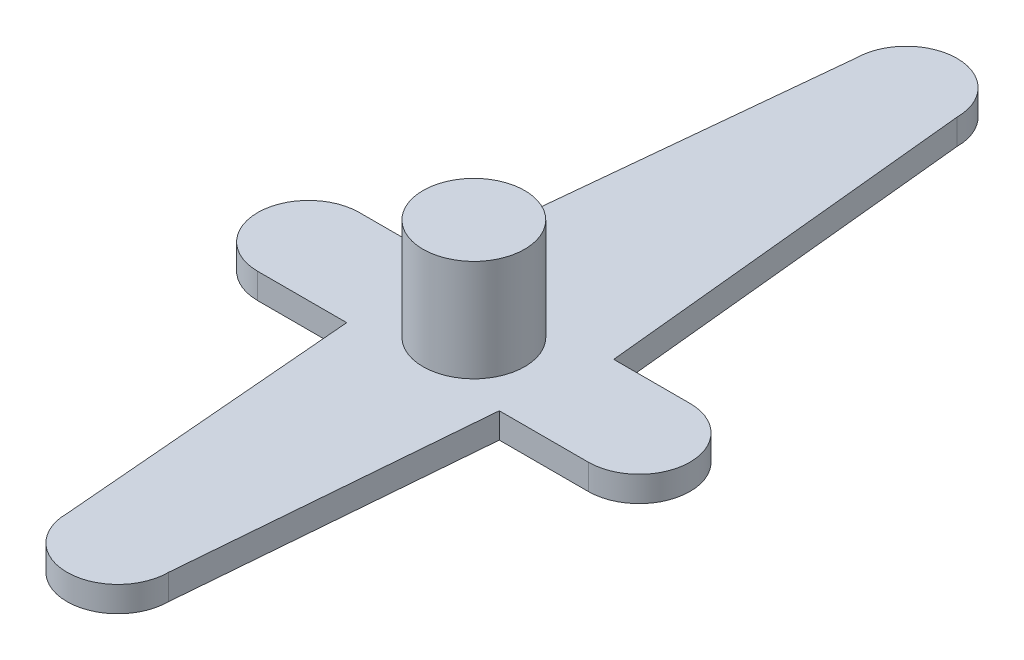
from build123d import *

# Parameters (mm, degrees)
BOSS_EXTRUDE1_DEPTH = 1
SKETCH2_R           = 2
BOSS_EXTRUDE2_DEPTH = 4


with BuildPart() as part:
    # Sketch1 → Boss-Extrude1 (new body)
    with BuildSketch(Plane(origin=(0, 0, 0), x_dir=(1, 0, 0), z_dir=(0, 1, 0))):
        with BuildLine():
            Line((-3.5, 2), (-6.5, 2))
            ThreePointArc((-6.5, 2), (-8.5, 0), (-6.5, -2))
            Line((-6.5, -2), (-3, -2))
            Line((-3, -2), (-2, -14))
            ThreePointArc((-2, -14), (0, -16), (2, -14))
            Line((2, -14), (3, -2))
            Line((3, -2), (6.5, -2))
            ThreePointArc((6.5, -2), (8.5, 0), (6.5, 2))
            Line((6.5, 2), (3.5, 2))
            Line((3.5, 2), (2, 17))
            ThreePointArc((2, 17), (0, 19), (-2, 17))
            Line((-2, 17), (-3.5, 2))
        make_face()
    extrude(amount=BOSS_EXTRUDE1_DEPTH)

    # Sketch2 → Boss-Extrude2 (add)
    with BuildSketch(Plane(origin=(0, 1, 0), x_dir=(1, 0, 0), z_dir=(0, 1, 0))):
        Circle(SKETCH2_R)
    extrude(amount=BOSS_EXTRUDE2_DEPTH)


solid = part.part
